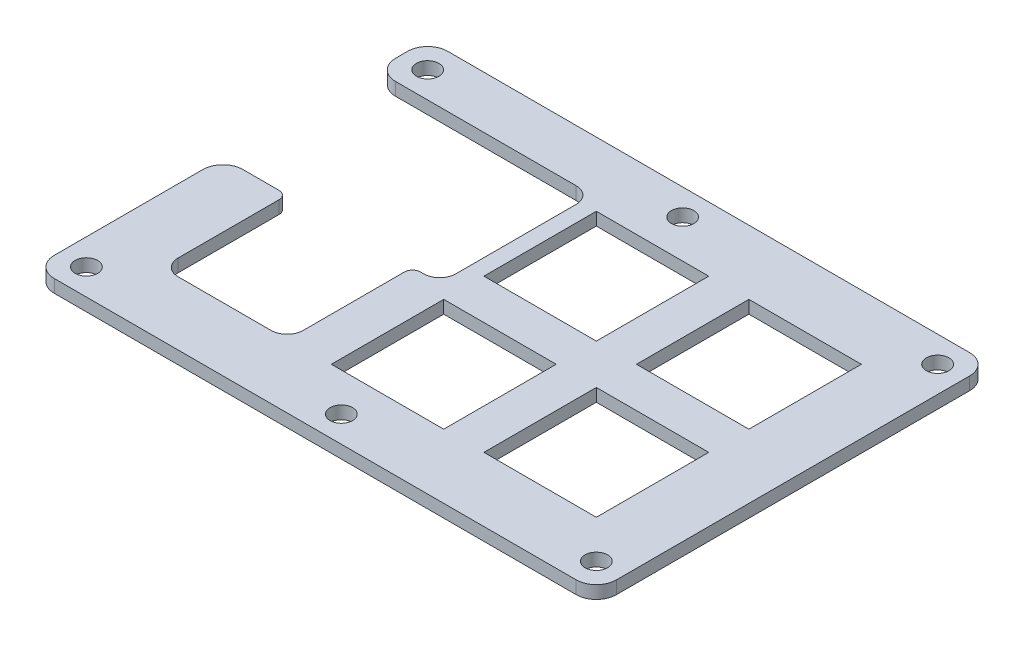
from build123d import *

# Parameters (mm, degrees)
SKETCH1_W            = 40
SKETCH1_H            = 39
BOSS_EXTRUDE1_DEPTH  = 1.6
SKETCH3_W            = 70
SKETCH3_H            = 49
BOSS_EXTRUDE2_DEPTH  = 1.6
SKETCH4_W            = 27
SKETCH4_H            = 19
CUT_EXTRUDE1_DEPTH   = 2.6
FILLET1_R            = 2
SKETCH5_W            = 15.6
SKETCH5_H            = 15.6
CUT_EXTRUDE2_DEPTH   = 2.6
FILLET2_R            = 2
FILLET3_R            = 1
SKETCH6_R            = 1.4
CUT_EXTRUDE3_DEPTH   = 2.6
FILLET4_R            = 2.5
SKETCH7_W            = 14
SKETCH7_H            = 14
CUT_EXTRUDE4_DEPTH   = 2.6
LPATTERN1_COUNT      = 2
LPATTERN1_PITCH      = 19
LPATTERN1_COUNT_DIR2 = 2
LPATTERN1_PITCH_DIR2 = 19


with BuildPart() as part:
    # Sketch1 → Boss-Extrude1 (new body)
    with BuildSketch(Plane(origin=(0, 0, 0), x_dir=(1, 0, 0), z_dir=(0, 1, 0))):
        Rectangle(SKETCH1_W, SKETCH1_H)
    extrude(amount=BOSS_EXTRUDE1_DEPTH)

    # Sketch3 → Boss-Extrude2 (add)
    with BuildSketch(Plane(origin=(0, 0, 0), x_dir=(1, 0, 0), z_dir=(0, 1, 0))):
        with Locations((-10, 0)):
            Rectangle(SKETCH3_W, SKETCH3_H)
    extrude(amount=BOSS_EXTRUDE2_DEPTH)

    # Sketch4 → Cut-Extrude1 (cut, through all)
    with BuildSketch(Plane(origin=(0, 1.6, 0), x_dir=(1, 0, 0), z_dir=(0, 1, 0))):
        with Locations((-31.5, 8.5)):
            Rectangle(SKETCH4_W, SKETCH4_H)
    extrude(amount=-CUT_EXTRUDE1_DEPTH, mode=Mode.SUBTRACT)

    # Fillet1
    fillet1_edges = [part.edges().sort_by_distance(p)[0] for p in [
        (-18, 0.8, -18),
        (-18, 0.8, 1),
    ]]
    fillet(fillet1_edges, radius=FILLET1_R)

    # Sketch5 → Cut-Extrude2 (cut, through all)
    with BuildSketch(Plane(origin=(0, 1.6, 0), x_dir=(1, 0, 0), z_dir=(0, 1, 0))):
        with Locations((-29.2, -8.8)):
            Rectangle(SKETCH5_W, SKETCH5_H)
    extrude(amount=-CUT_EXTRUDE2_DEPTH, mode=Mode.SUBTRACT)

    # Fillet2
    fillet2_edges = [part.edges().sort_by_distance(p)[0] for p in [
        (-37, 0.8, 16.6),
        (-21.4, 0.8, 16.6),
    ]]
    fillet(fillet2_edges, radius=FILLET2_R)

    # Fillet3
    fillet3_edges = [part.edges().sort_by_distance(p)[0] for p in [
        (-37, 0.8, 1),
        (-21.4, 0.8, 1),
    ]]
    fillet(fillet3_edges, radius=FILLET3_R)

    # Sketch6 → Cut-Extrude3 (cut, through all)
    with BuildSketch(Plane(origin=(0, 1.6, 0), x_dir=(1, 0, 0), z_dir=(0, 1, 0))):
        with Locations((-41.75, 21.25)):
            Circle(SKETCH6_R)
        with Locations((21.75, 21.25)):
            Circle(SKETCH6_R)
        with Locations((21.75, -21.25)):
            Circle(SKETCH6_R)
        with Locations((-41.75, -21.25)):
            Circle(SKETCH6_R)
        with Locations((-10, -21.25)):
            Circle(SKETCH6_R)
        with Locations((-10, 21.25)):
            Circle(SKETCH6_R)
    extrude(amount=-CUT_EXTRUDE3_DEPTH, mode=Mode.SUBTRACT)

    # Fillet4
    fillet4_edges = [part.edges().sort_by_distance(p)[0] for p in [
        (25, 0.8, 24.5),
        (25, 0.8, -24.5),
        (-45, 0.8, -24.5),
        (-45, 0.8, 24.5),
        (-45, 0.8, 1),
        (-45, 0.8, -18),
    ]]
    fillet(fillet4_edges, radius=FILLET4_R)

    # Sketch7 → Cut-Extrude4 (cut, through all)
    with BuildSketch(Plane(origin=(0, 1.6, 0), x_dir=(1, 0, 0), z_dir=(0, 1, 0))):
        with Locations((-9, 9.5)):
            Rectangle(SKETCH7_W, SKETCH7_H)
    cut_extrude4 = extrude(amount=-CUT_EXTRUDE4_DEPTH, mode=Mode.SUBTRACT)

    # LPattern1: Cut-Extrude4 2 × 2
    with Locations(*[(i * LPATTERN1_PITCH, 0, j * LPATTERN1_PITCH_DIR2) for i in range(LPATTERN1_COUNT) for j in range(LPATTERN1_COUNT_DIR2) if (i, j) != (0, 0)]):
        add(cut_extrude4, mode=Mode.SUBTRACT)


solid = part.part
